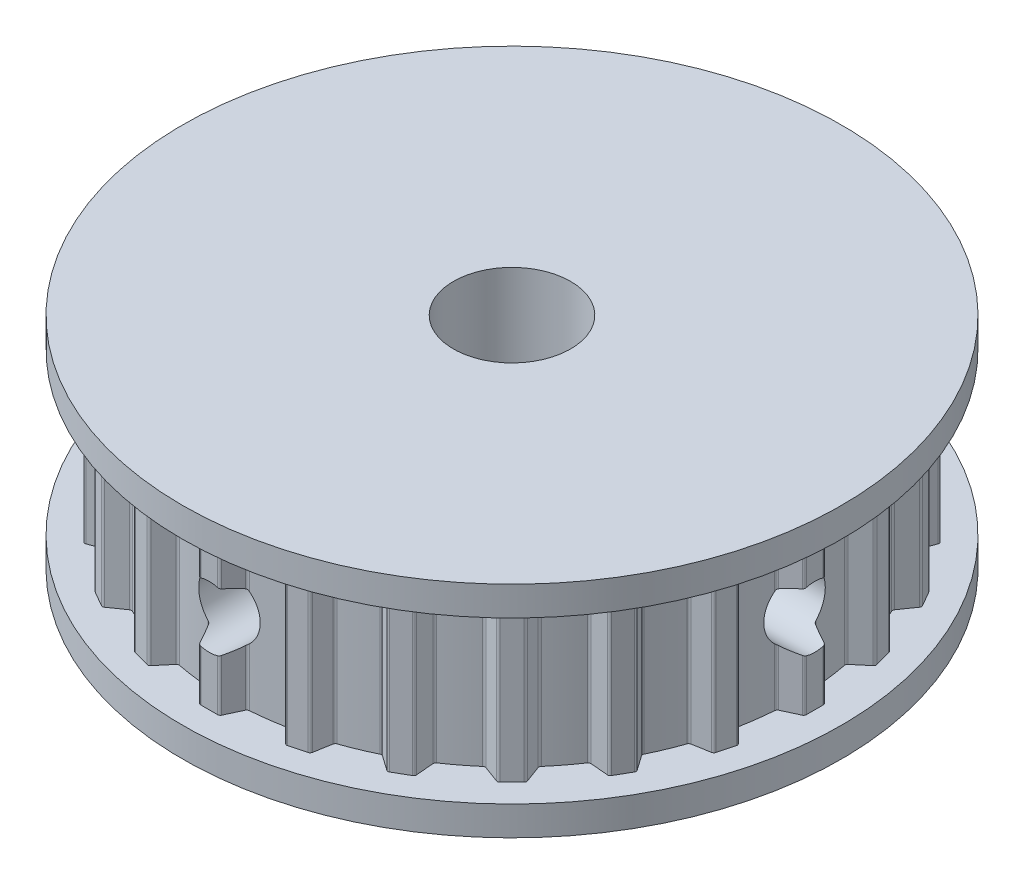
from build123d import *

# Parameters (mm, degrees)
SKETCH_1_R                       = 19.405
EXTRUDE_1_DEPTH                  = 5.5
EXTRUDE_1_DEPTH_BACK             = 5.5
EXTRUDE_5_DEPTH                  = 11
FILLET_1_R                       = 0.19
PATTERN_CIRCULAR_1_COUNT         = 24
FILLET_1_OF_PATTERN_CIRCULAR_1_R = 0.19
SKETCH_3_R                       = 22.5
EXTRUDE_3_DEPTH                  = 2
SKETCH_4_R                       = 22.5
EXTRUDE_4_DEPTH                  = 2
SKETCH_5_R                       = 4
CUT_EXTRUDE_1_DEPTH              = 36.178118199
M5X0_8_TAPPED_HOLE1_REACH        = 52.867
M5X0_8_TAPPED_HOLE1_BORE_R       = 2.1
CIRPATTERN1_COUNT                = 2
CIRPATTERN1_ANGLE                = 90


with BuildPart() as part:
    # Sketch 1 → Extrude 1 (new, two sides)
    with BuildSketch(Plane(origin=(0, 0, 0), x_dir=(1, 0, 0), z_dir=(0, 1, 0))) as extrude_1_sk:
        with Locations(Location((0, 0, 0), (0, 0, 270))):
            Circle(SKETCH_1_R)
    extrude(amount=EXTRUDE_1_DEPTH)
    extrude(extrude_1_sk.sketch, amount=-EXTRUDE_1_DEPTH_BACK)

    # Sketch 7 → Extrude 5 (add)
    with BuildSketch(Plane.XZ.offset(5.5)):
        Polygon((-1.751307658, -18.405), (1.751307658, -18.405), (0.692789274, -20.675), (-0.692789274, -20.675), align=None)
    extrude_5 = extrude(amount=-EXTRUDE_5_DEPTH)

    # Fillet 1
    fillet_1_edges = [part.edges().sort_by_distance(p)[0] for p in [
        (1.305501026, 2.75, -19.361035408),
        (0.692789274, 0, -20.675),
        (-1.305501026, 2.75, -19.361035408),
        (-0.692789274, 0, -20.675),
    ]]
    fillet(fillet_1_edges, radius=FILLET_1_R)

    # Pattern Circular 1: Extrude 5 ×24 about axis
    pattern_circular_1_axis = Axis((0, 0, 0), (0, 1, 0))
    for i in range(1, PATTERN_CIRCULAR_1_COUNT):
        add(extrude_5.rotate(pattern_circular_1_axis, i * 360 / PATTERN_CIRCULAR_1_COUNT))

    # Fillet 1 of Pattern Circular 1
    fillet_1_of_pattern_circular_1_edges = [part.edges().sort_by_distance(p)[0] for p in [
        (-3.749987539, 2.75, -19.039212653),
        (-4.681900705, 0, -20.149823517),
        (-6.272021854, 2.75, -18.363435595),
        (-6.02026681, 0, -19.7912094),
        (-8.549920651, 2.75, -17.41989902),
        (-9.737526889, 0, -18.25146986),
        (-10.811114757, 2.75, -16.114397994),
        (-10.937473111, 0, -17.558680586),
        (-12.7671908, 2.75, -14.613448056),
        (-14.129556707, 0, -15.109308695),
        (-14.613448056, 2.75, -12.7671908),
        (-15.109308695, 0, -14.129556707),
        (-16.114397994, 2.75, -10.811114757),
        (-17.558680586, 0, -10.937473111),
        (-17.41989902, 2.75, -8.549920651),
        (-18.25146986, 0, -9.737526889),
        (-18.363435595, 2.75, -6.272021854),
        (-19.7912094, 0, -6.02026681),
        (-19.039212653, 2.75, -3.749987539),
        (-20.149823517, 0, -4.681900705),
        (-19.361035408, 2.75, -1.305501026),
        (-20.675, 0, -0.692789274),
        (-19.361035408, 2.75, 1.305501026),
        (-20.675, 0, 0.692789274),
        (-19.039212653, 2.75, 3.749987539),
        (-20.149823517, 0, 4.681900705),
        (-18.363435595, 2.75, 6.272021854),
        (-19.7912094, 0, 6.02026681),
        (-17.41989902, 2.75, 8.549920651),
        (-18.25146986, 0, 9.737526889),
        (-16.114397994, 2.75, 10.811114757),
        (-17.558680586, 0, 10.937473111),
        (-14.613448056, 2.75, 12.7671908),
        (-15.109308695, 0, 14.129556707),
        (-12.7671908, 2.75, 14.613448056),
        (-14.129556707, 0, 15.109308695),
        (-10.811114757, 2.75, 16.114397994),
        (-10.937473111, 0, 17.558680586),
        (-8.549920651, 2.75, 17.41989902),
        (-9.737526889, 0, 18.25146986),
        (-6.272021854, 2.75, 18.363435595),
        (-6.02026681, 0, 19.7912094),
        (-3.749987539, 2.75, 19.039212653),
        (-4.681900705, 0, 20.149823517),
        (-1.305501026, 2.75, 19.361035408),
        (-0.692789274, 0, 20.675),
        (1.305501026, 2.75, 19.361035408),
        (0.692789274, 0, 20.675),
        (3.749987539, 2.75, 19.039212653),
        (4.681900705, 0, 20.149823517),
        (6.272021854, 2.75, 18.363435595),
        (6.02026681, 0, 19.7912094),
        (8.549920651, 2.75, 17.41989902),
        (9.737526889, 0, 18.25146986),
        (10.811114757, 2.75, 16.114397994),
        (10.937473111, 0, 17.558680586),
        (12.7671908, 2.75, 14.613448056),
        (14.129556707, 0, 15.109308695),
        (14.613448056, 2.75, 12.7671908),
        (15.109308695, 0, 14.129556707),
        (16.114397994, 2.75, 10.811114757),
        (17.558680586, 0, 10.937473111),
        (17.41989902, 2.75, 8.549920651),
        (18.25146986, 0, 9.737526889),
        (18.363435595, 2.75, 6.272021854),
        (19.7912094, 0, 6.02026681),
        (19.039212653, 2.75, 3.749987539),
        (20.149823517, 0, 4.681900705),
        (19.361035408, 2.75, 1.305501026),
        (20.675, 0, 0.692789274),
        (19.361035408, 2.75, -1.305501026),
        (20.675, 0, -0.692789274),
        (19.039212653, 2.75, -3.749987539),
        (20.149823517, 0, -4.681900705),
        (18.363435595, 2.75, -6.272021854),
        (19.7912094, 0, -6.02026681),
        (17.41989902, 2.75, -8.549920651),
        (18.25146986, 0, -9.737526889),
        (16.114397994, 2.75, -10.811114757),
        (17.558680586, 0, -10.937473111),
        (14.613448056, 2.75, -12.7671908),
        (15.109308695, 0, -14.129556707),
        (12.7671908, 2.75, -14.613448056),
        (14.129556707, 0, -15.109308695),
        (10.811114757, 2.75, -16.114397994),
        (10.937473111, 0, -17.558680586),
        (8.549920651, 2.75, -17.41989902),
        (9.737526889, 0, -18.25146986),
        (6.272021854, 2.75, -18.363435595),
        (6.02026681, 0, -19.7912094),
        (3.749987539, 2.75, -19.039212653),
        (4.681900705, 0, -20.149823517),
    ]]
    fillet(fillet_1_of_pattern_circular_1_edges, radius=FILLET_1_OF_PATTERN_CIRCULAR_1_R)

    # Sketch 3 → Extrude 3 (add)
    with BuildSketch(Plane.XZ.offset(5.5)):
        with Locations(Location((0, 0, 0), (0, 0, 270))):
            Circle(SKETCH_3_R)
    extrude(amount=EXTRUDE_3_DEPTH)

    # Sketch 4 → Extrude 4 (add)
    with BuildSketch(Plane(origin=(0, 5.5, 0), x_dir=(1, 0, 0), z_dir=(0, 1, 0))):
        with Locations(Location((0, 0, 0), (0, 0, 90))):
            Circle(SKETCH_4_R)
    extrude(amount=EXTRUDE_4_DEPTH)

    # Sketch 5 → Cut-Extrude 1 (cut, through all)
    with BuildSketch(Plane.XZ.offset(7.5)):
        with Locations(Location((0, 0, 0), (0, 0, 270))):
            Circle(SKETCH_5_R)
    extrude(amount=-CUT_EXTRUDE_1_DEPTH, mode=Mode.SUBTRACT)

    # M5x0.8 Tapped Hole1 bore → M5x0.8 Tapped Hole1 (cut, up to next)
    with BuildSketch(Plane.XY.offset(22.5), mode=Mode.PRIVATE) as m5x0_8_tapped_hole1_sk1:
        Circle(M5X0_8_TAPPED_HOLE1_BORE_R)
    m5x0_8_tapped_hole1_tool1 = extrude(m5x0_8_tapped_hole1_sk1.sketch, amount=-M5X0_8_TAPPED_HOLE1_REACH, mode=Mode.PRIVATE) & part.part
    m5x0_8_tapped_hole1 = m5x0_8_tapped_hole1_tool1.solids().sort_by_distance((0, 0, 22.5))[0]
    add(m5x0_8_tapped_hole1, mode=Mode.SUBTRACT)

    # CirPattern1: M5x0.8 Tapped Hole1 ×2 about axis
    cirpattern1_axis = Axis((0, 7.5, 0), (0, 1, 0))
    for i in range(1, CIRPATTERN1_COUNT):
        add(m5x0_8_tapped_hole1.rotate(cirpattern1_axis, i * CIRPATTERN1_ANGLE / (CIRPATTERN1_COUNT - 1)), mode=Mode.SUBTRACT)


solid = part.part
